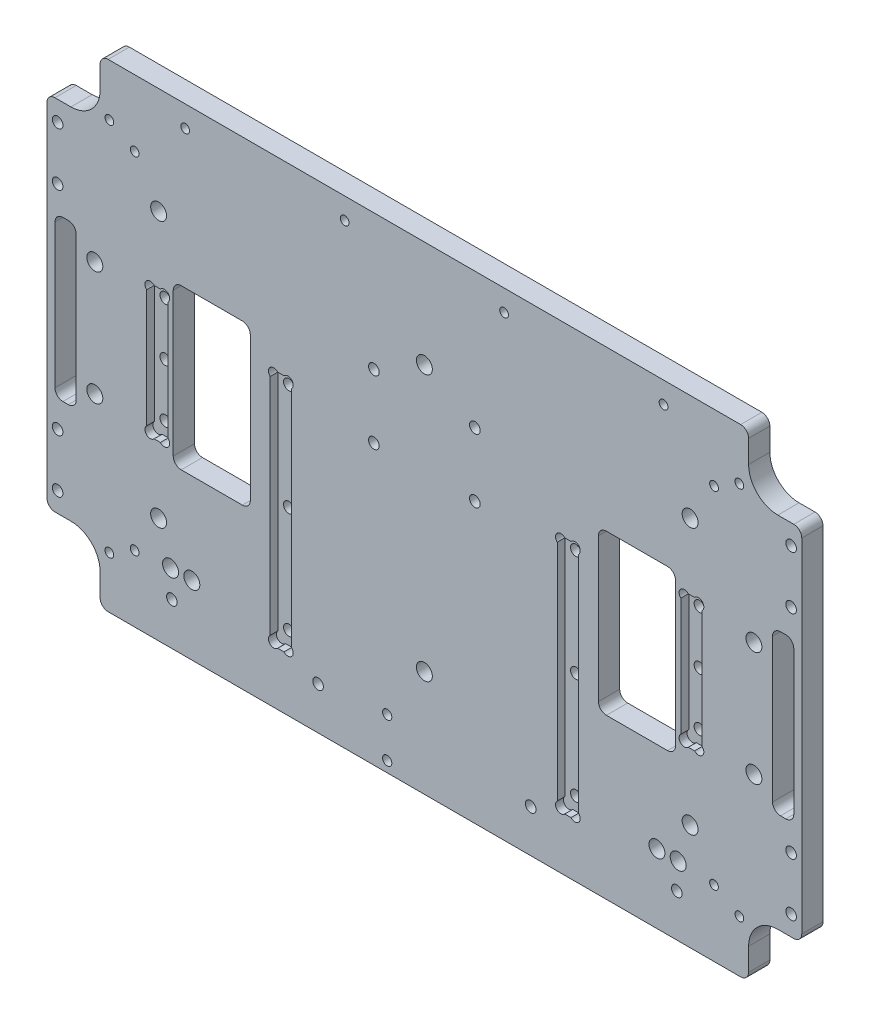
from build123d import *

# Parameters (mm, degrees)
ESQUISSE1_W                  = 284
ESQUISSE1_H                  = 180
BOSS_EXTRU_1_DEPTH           = 8
ESQUISSE2_W                  = 29
ESQUISSE2_H                  = 60
ESQUISSE2_W_2                = 8
ENL_V_MAT_EXTRU_1_DEPTH      = 9
ESQUISSE3_R                  = 1.65
ENL_V_MAT_EXTRU_2_DEPTH      = 8
ESQUISSE4_W                  = 8
ESQUISSE4_H                  = 90
ESQUISSE4_H_2                = 50
ENL_V_MAT_EXTRU_3_DEPTH      = 3
ESQUISSE5_R                  = 2
ENL_V_MAT_EXTRU_4_DEPTH      = 9
ESQUISSE6_R                  = 3
ENL_V_MAT_EXTRU_5_DEPTH      = 9
ESQUISSE8_W                  = 20
ESQUISSE8_H                  = 22.5
ENL_V_MAT_EXTRU_7_DEPTH      = 9
CONG_1_R                     = 11
ESQUISSE7_R                  = 1.65
ENL_V_MAT_EXTRU_6_DEPTH      = 9
CONG_2_R                     = 3
ESQUISSE9_R                  = 2
ENL_V_MAT_EXTRU_8_DEPTH      = 3
CONG_3_R                     = 3
ESQUISSE10_R                 = 2
ENL_V_MAT_EXTRU_9_DEPTH      = 6
ESQUISSE11_R                 = 2
ESQUISSE11_R_2               = 3
ENL_V_MAT_EXTRU_10_DEPTH     = 9
ESQUISSE12_R                 = 1.75
ENL_V_MAT_EXTRU_11_DEPTH     = 9
ESQUISSE13_R                 = 2
ENL_V_MAT_EXTRU_12_DEPTH     = 9
ESQUISSE14_R                 = 3
FIXATIONS_USINAGE_DEPTH      = 1
FIXATIONS_USINAGE_DEPTH_BACK = 9


with BuildPart() as part:
    # Esquisse1 → Boss.-Extru.1 (new body)
    with BuildSketch(Plane.XY):
        with Locations((142, 90)):
            Rectangle(ESQUISSE1_W, ESQUISSE1_H)
    extrude(amount=BOSS_EXTRU_1_DEPTH)

    # Esquisse2 → Enlèv. mat.-Extru.1 (cut, through all)
    with BuildSketch(Plane.XY.offset(8)):
        with Locations((62, 90)):
            Rectangle(ESQUISSE2_W, ESQUISSE2_H)
        with Locations((7, 90)):
            Rectangle(ESQUISSE2_W_2, ESQUISSE2_H)
        with Locations((277, 90)):
            Rectangle(ESQUISSE2_W_2, ESQUISSE2_H)
        with Locations((222, 90)):
            Rectangle(ESQUISSE2_W, ESQUISSE2_H)
    extrude(amount=-ENL_V_MAT_EXTRU_1_DEPTH, mode=Mode.SUBTRACT)

    # Esquisse3 → Enlèv. mat.-Extru.2 (cut)
    with BuildSketch(Plane.XY.offset(8)):
        with Locations((112, 172)):
            Circle(ESQUISSE3_R)
        with Locations((172, 172)):
            Circle(ESQUISSE3_R)
        with Locations((232, 172)):
            Circle(ESQUISSE3_R)
        with Locations((52, 172)):
            Circle(ESQUISSE3_R)
    extrude(amount=-ENL_V_MAT_EXTRU_2_DEPTH, mode=Mode.SUBTRACT)

    # Esquisse4 → Enlèv. mat.-Extru.3 (cut)
    with BuildSketch(Plane.XY.offset(8)):
        with Locations((88, 65)):
            Rectangle(ESQUISSE4_W, ESQUISSE4_H)
        with Locations((196, 65)):
            Rectangle(ESQUISSE4_W, ESQUISSE4_H)
        with Locations((41.5, 90)):
            Rectangle(ESQUISSE4_W, ESQUISSE4_H_2)
        with Locations((242.5, 90)):
            Rectangle(ESQUISSE4_W, ESQUISSE4_H_2)
    extrude(amount=-ENL_V_MAT_EXTRU_3_DEPTH, mode=Mode.SUBTRACT)

    # Esquisse5 → Enlèv. mat.-Extru.4 (cut, through all)
    with BuildSketch(Plane.XY.offset(8)):
        with Locations((123, 129)):
            Circle(ESQUISSE5_R)
        with Locations((123, 105)):
            Circle(ESQUISSE5_R)
        with Locations((161, 105)):
            Circle(ESQUISSE5_R)
        with Locations((161, 129)):
            Circle(ESQUISSE5_R)
    extrude(amount=-ENL_V_MAT_EXTRU_4_DEPTH, mode=Mode.SUBTRACT)

    # Esquisse6 → Enlèv. mat.-Extru.5 (cut, through all)
    with BuildSketch(Plane.XY.offset(8)):
        with Locations((18, 111.5)):
            Circle(ESQUISSE6_R)
        with Locations((18, 68.5)):
            Circle(ESQUISSE6_R)
        with Locations((266, 68.5)):
            Circle(ESQUISSE6_R)
        with Locations((266, 111.5)):
            Circle(ESQUISSE6_R)
    extrude(amount=-ENL_V_MAT_EXTRU_5_DEPTH, mode=Mode.SUBTRACT)

    # Esquisse8 → Enlèv. mat.-Extru.7 (cut, through all)
    with BuildSketch(Plane.XY.offset(8)):
        with Locations((10, 168.75)):
            Rectangle(ESQUISSE8_W, ESQUISSE8_H)
        with Locations((274, 168.75)):
            Rectangle(ESQUISSE8_W, ESQUISSE8_H)
        with Locations((274, 11.25)):
            Rectangle(ESQUISSE8_W, ESQUISSE8_H)
        with Locations((10, 11.25)):
            Rectangle(ESQUISSE8_W, ESQUISSE8_H)
    extrude(amount=-ENL_V_MAT_EXTRU_7_DEPTH, mode=Mode.SUBTRACT)

    # Congé1
    cong_1_edges = [part.edges().sort_by_distance(p)[0] for p in [
        (20, 157.5, 4),
        (264, 157.5, 4),
        (20, 22.5, 4),
        (264, 22.5, 4),
    ]]
    fillet(cong_1_edges, radius=CONG_1_R)

    # Esquisse7 → Enlèv. mat.-Extru.6 (cut, through all)
    with BuildSketch(Plane.XY.offset(8)):
        with Locations((33, 155)):
            Circle(ESQUISSE7_R)
        with Locations((23.473720558, 160.5)):
            Circle(ESQUISSE7_R)
        with Locations((260.526279442, 160.5)):
            Circle(ESQUISSE7_R)
        with Locations((251, 155)):
            Circle(ESQUISSE7_R)
        with Locations((23.473720558, 19.5)):
            Circle(ESQUISSE7_R)
        with Locations((33, 25)):
            Circle(ESQUISSE7_R)
        with Locations((251, 25)):
            Circle(ESQUISSE7_R)
        with Locations((260.526279442, 19.5)):
            Circle(ESQUISSE7_R)
    extrude(amount=-ENL_V_MAT_EXTRU_6_DEPTH, mode=Mode.SUBTRACT)

    # Congé2
    cong_2_edges = [part.edges().sort_by_distance(p)[0] for p in [
        (47.5, 60, 4),
        (47.5, 120, 4),
        (76.5, 120, 4),
        (76.5, 60, 4),
        (3, 60, 4),
        (3, 120, 4),
        (11, 120, 4),
        (11, 60, 4),
        (281, 60, 4),
        (273, 60, 4),
        (273, 120, 4),
        (281, 120, 4),
        (236.5, 60, 4),
        (207.5, 60, 4),
        (207.5, 120, 4),
        (236.5, 120, 4),
    ]]
    fillet(cong_2_edges, radius=CONG_2_R)

    # Esquisse9 → Enlèv. mat.-Extru.8 (cut)
    with BuildSketch(Plane.XY.offset(8)):
        with Locations((38.843502884, 113.656497116)):
            Circle(ESQUISSE9_R)
        with Locations((44.156497116, 113.656497116)):
            Circle(ESQUISSE9_R)
        with Locations((44.156497116, 66.343502884)):
            Circle(ESQUISSE9_R)
        with Locations((38.843502884, 66.343502884)):
            Circle(ESQUISSE9_R)
        with Locations((245.156497116, 66.343502884)):
            Circle(ESQUISSE9_R)
        with Locations((239.843502884, 66.343502884)):
            Circle(ESQUISSE9_R)
        with Locations((239.843502884, 113.656497116)):
            Circle(ESQUISSE9_R)
        with Locations((245.156497116, 113.656497116)):
            Circle(ESQUISSE9_R)
        with Locations((85.343502884, 108.656497116)):
            Circle(ESQUISSE9_R)
        with Locations((90.656497116, 108.656497116)):
            Circle(ESQUISSE9_R)
        with Locations((90.656497116, 21.343502884)):
            Circle(ESQUISSE9_R)
        with Locations((85.343502884, 21.343502884)):
            Circle(ESQUISSE9_R)
        with Locations((198.656497116, 21.343502884)):
            Circle(ESQUISSE9_R)
        with Locations((193.343502884, 21.343502884)):
            Circle(ESQUISSE9_R)
        with Locations((193.343502884, 108.656497116)):
            Circle(ESQUISSE9_R)
        with Locations((198.656497116, 108.656497116)):
            Circle(ESQUISSE9_R)
    extrude(amount=-ENL_V_MAT_EXTRU_8_DEPTH, mode=Mode.SUBTRACT)

    # Congé3
    cong_3_edges = [part.edges().sort_by_distance(p)[0] for p in [
        (0, 157.5, 4),
        (20, 180, 4),
        (264, 180, 4),
        (284, 157.5, 4),
        (0, 22.5, 4),
        (20, 0, 4),
        (264, 0, 4),
        (284, 22.5, 4),
    ]]
    fillet(cong_3_edges, radius=CONG_3_R)

    # Esquisse10 → Enlèv. mat.-Extru.9 (cut, through all)
    with BuildSketch(Plane.XY.offset(5)):
        with Locations((41.5, 90)):
            Circle(ESQUISSE10_R)
        with Locations((41.5, 70)):
            Circle(ESQUISSE10_R)
        with Locations((41.5, 110)):
            Circle(ESQUISSE10_R)
        with Locations((88, 65)):
            Circle(ESQUISSE10_R)
        with Locations((88, 25)):
            Circle(ESQUISSE10_R)
        with Locations((88, 105)):
            Circle(ESQUISSE10_R)
        with Locations((196, 105)):
            Circle(ESQUISSE10_R)
        with Locations((196, 25)):
            Circle(ESQUISSE10_R)
        with Locations((196, 65)):
            Circle(ESQUISSE10_R)
        with Locations((242.5, 110)):
            Circle(ESQUISSE10_R)
        with Locations((242.5, 70)):
            Circle(ESQUISSE10_R)
        with Locations((242.5, 90)):
            Circle(ESQUISSE10_R)
    extrude(amount=-ENL_V_MAT_EXTRU_9_DEPTH, mode=Mode.SUBTRACT)

    # Esquisse11 → Enlèv. mat.-Extru.10 (cut, through all)
    with BuildSketch(Plane.XY.offset(8)):
        with Locations((47, 16)):
            Circle(ESQUISSE11_R)
        with Locations((237, 16)):
            Circle(ESQUISSE11_R)
        with Locations((102, 16)):
            Circle(ESQUISSE11_R)
        with Locations((46.5, 26)):
            Circle(ESQUISSE11_R_2)
        with Locations((54.5, 26)):
            Circle(ESQUISSE11_R_2)
        with Locations((229.5, 26)):
            Circle(ESQUISSE11_R_2)
        with Locations((237.5, 26)):
            Circle(ESQUISSE11_R_2)
        with Locations((182, 16)):
            Circle(ESQUISSE11_R)
    extrude(amount=-ENL_V_MAT_EXTRU_10_DEPTH, mode=Mode.SUBTRACT)

    # Esquisse12 → Enlèv. mat.-Extru.11 (cut, through all)
    with BuildSketch(Plane.XY.offset(8)):
        with Locations((128, 4)):
            Circle(ESQUISSE12_R)
        with Locations((128, 19)):
            Circle(ESQUISSE12_R)
    extrude(amount=-ENL_V_MAT_EXTRU_11_DEPTH, mode=Mode.SUBTRACT)

    # Esquisse13 → Enlèv. mat.-Extru.12 (cut, through all)
    with BuildSketch(Plane.XY.offset(8)):
        with Locations((4, 30)):
            Circle(ESQUISSE13_R)
        with Locations((4, 50)):
            Circle(ESQUISSE13_R)
        with Locations((4, 130)):
            Circle(ESQUISSE13_R)
        with Locations((4, 150)):
            Circle(ESQUISSE13_R)
        with Locations((280, 150)):
            Circle(ESQUISSE13_R)
        with Locations((280, 130)):
            Circle(ESQUISSE13_R)
        with Locations((280, 50)):
            Circle(ESQUISSE13_R)
        with Locations((280, 30)):
            Circle(ESQUISSE13_R)
    extrude(amount=-ENL_V_MAT_EXTRU_12_DEPTH, mode=Mode.SUBTRACT)

    # Esquisse14 → fixations_usinage (cut, two sides)
    with BuildSketch(Plane.XY.offset(8)) as fixations_usinage_sk:
        with Locations((42, 140)):
            Circle(ESQUISSE14_R)
        with Locations((42, 40)):
            Circle(ESQUISSE14_R)
        with Locations((242, 40)):
            Circle(ESQUISSE14_R)
        with Locations((242, 140)):
            Circle(ESQUISSE14_R)
        with Locations((142, 40)):
            Circle(ESQUISSE14_R)
        with Locations((142, 140)):
            Circle(ESQUISSE14_R)
    extrude(amount=FIXATIONS_USINAGE_DEPTH, mode=Mode.SUBTRACT)
    extrude(fixations_usinage_sk.sketch, amount=-FIXATIONS_USINAGE_DEPTH_BACK, mode=Mode.SUBTRACT)


solid = part.part
